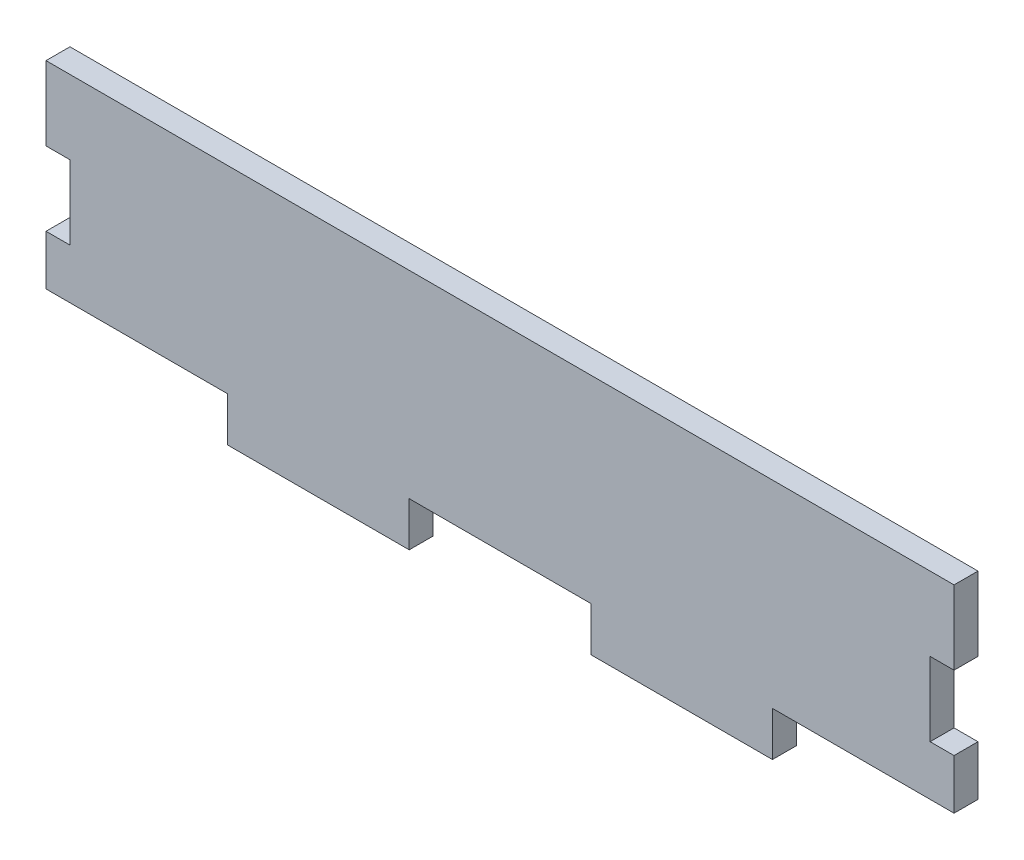
from build123d import *

# Parameters (mm, degrees)
BOSS_EXTRUDE1_DEPTH = 2.7


with BuildPart() as part:
    # Sketch1 → Boss-Extrude1 (new body)
    with BuildSketch(Plane.XY):
        Polygon((-51.2, -9.8), (-51.2, -4.166666667), (-48.5, -4.166666667), (-48.5, 4.166666667), (-51.2, 4.166666667), (-51.2, 12.5), (51.2, 12.5), (51.2, 4.166666667), (48.5, 4.166666667), (48.5, -4.166666667), (51.2, -4.166666667), (51.2, -9.8), (30.72, -9.8), (30.72, -12.5), (30.72, -14.8), (10.24, -14.8), (10.24, -12.5), (10.24, -9.8), (-10.24, -9.8), (-10.24, -12.5), (-10.24, -14.8), (-30.72, -14.8), (-30.72, -12.5), (-30.72, -9.8), align=None)
    extrude(amount=BOSS_EXTRUDE1_DEPTH)


solid = part.part
